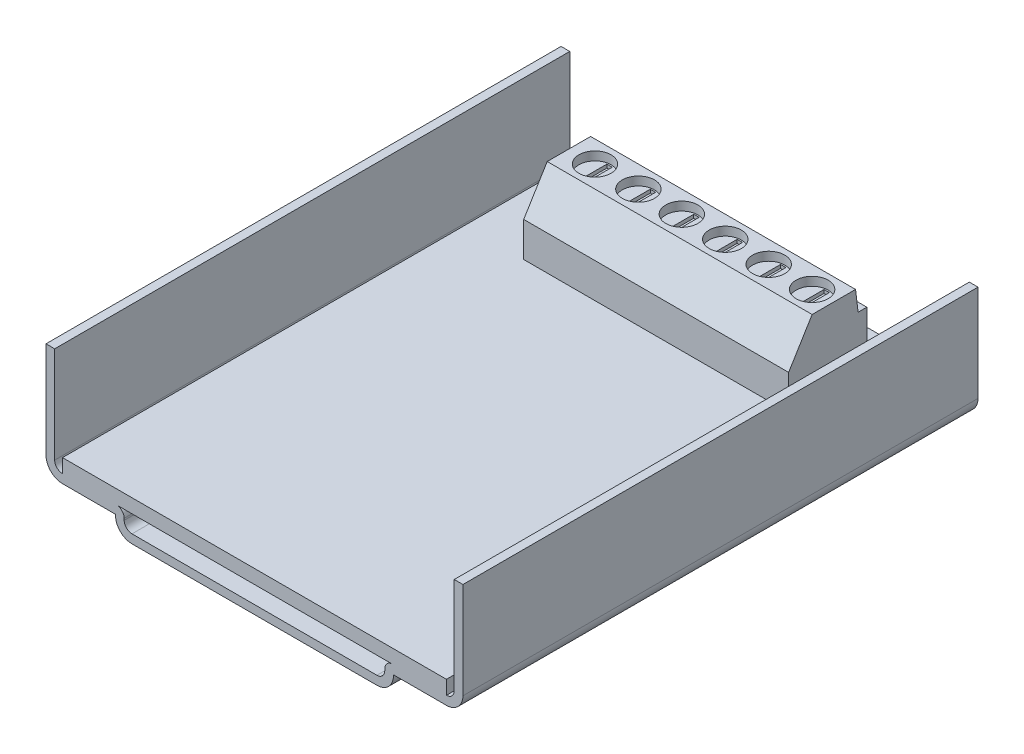
from build123d import *

# Parameters (mm, degrees)
EXTRUDE_THIN1_DEPTH = 59.3
SKETCH2_W           = 44.2
SKETCH2_H           = 59.3
EXTRUDE1_DEPTH      = 1.6
EXTRUDE2_DEPTH      = 30.5
SKETCH4_R           = 1.85
EXTRUDE3_DEPTH      = 1.5
SKETCH6_R           = 1.85
EXTRUDE4_DEPTH      = 0.5
SKETCH8_W           = 0.615121557
SKETCH8_H           = 3.349209548
EXTRUDE5_DEPTH      = 0.4
LPATTERN1_COUNT     = 6
LPATTERN1_PITCH     = 5


with BuildPart() as part:
    # Sketch1 → Extrude-Thin1 (new body)
    with BuildSketch(Plane.XY):
        with BuildLine():
            Line((-28.323886885, 14), (-28.323886885, 2.9))
            ThreePointArc((-28.323886885, 2.9), (-28.060282988, 2.263603897), (-27.423886885, 2))
            Line((-27.423886885, 2), (-21.223886885, 2))
            ThreePointArc((-21.223886885, 2), (-20.587490782, 1.736396103), (-20.323886885, 1.1))
            Line((-20.323886885, 1.1), (-20.323886885, 0.9))
            ThreePointArc((-20.323886885, 0.9), (-20.060282988, 0.263603897), (-19.423886885, 0))
            Line((-19.423886885, 0), (8.776113115, 0))
            ThreePointArc((8.776113115, 0), (9.412509218, 0.263603897), (9.676113115, 0.9))
            Line((9.676113115, 0.9), (9.676113115, 1.1))
            ThreePointArc((9.676113115, 1.1), (9.939717012, 1.736396103), (10.576113115, 2))
            Line((10.576113115, 2), (16.776113115, 2))
            ThreePointArc((16.776113115, 2), (17.412509218, 2.263603897), (17.676113115, 2.9))
            Line((17.676113115, 2.9), (17.676113115, 14))
            Line((17.676113115, 14), (18.676113115, 14))
            Line((18.676113115, 14), (18.676113115, 2.9))
            ThreePointArc((18.676113115, 2.9), (18.119615999, 1.556497116), (16.776113115, 1))
            Line((16.776113115, 1), (10.676113115, 1))
            Line((10.676113115, 1), (10.676113115, 0.9))
            ThreePointArc((10.676113115, 0.9), (10.119615999, -0.443502884), (8.776113115, -1))
            Line((8.776113115, -1), (-19.423886885, -1))
            ThreePointArc((-19.423886885, -1), (-20.767389769, -0.443502884), (-21.323886885, 0.9))
            Line((-21.323886885, 0.9), (-21.323886885, 1))
            Line((-21.323886885, 1), (-27.423886885, 1))
            ThreePointArc((-27.423886885, 1), (-28.767389769, 1.556497116), (-29.323886885, 2.9))
            Line((-29.323886885, 2.9), (-29.323886885, 14))
            Line((-29.323886885, 14), (-28.323886885, 14))
        make_face()
    extrude(amount=-EXTRUDE_THIN1_DEPTH)



with BuildPart() as body_2:
    # Sketch2 → Extrude1 (new body)
    with BuildSketch(Plane(origin=(0, 2, 0), x_dir=(1, 0, 0), z_dir=(0, 1, 0))):
        with Locations((-5.323886885, 29.65)):
            Rectangle(SKETCH2_W, SKETCH2_H)
    extrude(amount=EXTRUDE1_DEPTH)


with BuildPart() as part_1:
    add(part.part)

    add(body_2.part)  # Extrude2 merges body 2
    # Sketch3 → Extrude2 (add)
    with BuildSketch(Plane.ZY.offset(-9.876113115)):
        Polygon((-55.3, 3.6), (-46.3, 3.6), (-46.3, 7.6), (-49.003148697, 12.020138766), (-54.003148697, 12.020138766), (-54.3, 9.6), (-55.3, 9.6), align=None)
    extrude(amount=EXTRUDE2_DEPTH)

    # Sketch4 → Extrude3 (cut)
    with BuildSketch(Plane(origin=(0, 12.020138766, 0), x_dir=(1, 0, 0), z_dir=(0, 1, 0))):
        with Locations(Location((-17.623886885, 51.503148697, 0), (0, 0, 270))):
            Circle(SKETCH4_R)
    extrude3 = extrude(amount=-EXTRUDE3_DEPTH, mode=Mode.SUBTRACT)

    # Sketch6 → Extrude4 (add)
    with BuildSketch(Plane(origin=(0, 10.520138766, 0), x_dir=(1, 0, 0), z_dir=(0, 1, 0))):
        with Locations(Location((-17.623886885, 51.503148697, 0), (0, 0, 270))):
            Circle(SKETCH6_R)
    extrude4 = extrude(amount=EXTRUDE4_DEPTH)

    # Sketch8 → Extrude5 (cut)
    with BuildSketch(Plane(origin=(0, 11.020138766, 0), x_dir=(1, 0, 0), z_dir=(0, 1, 0))):
        with Locations((-17.623886885, 51.503148697)):
            Rectangle(SKETCH8_W, SKETCH8_H)
    extrude5 = extrude(amount=-EXTRUDE5_DEPTH, mode=Mode.SUBTRACT)

    # LPattern1: Extrude3, Extrude4, Extrude5 ×6
    with Locations(*[(i * LPATTERN1_PITCH, 0, 0) for i in range(1, LPATTERN1_COUNT)]):
        add(extrude3, mode=Mode.SUBTRACT)
        add(extrude4)
        add(extrude5, mode=Mode.SUBTRACT)


solid = part_1.part
